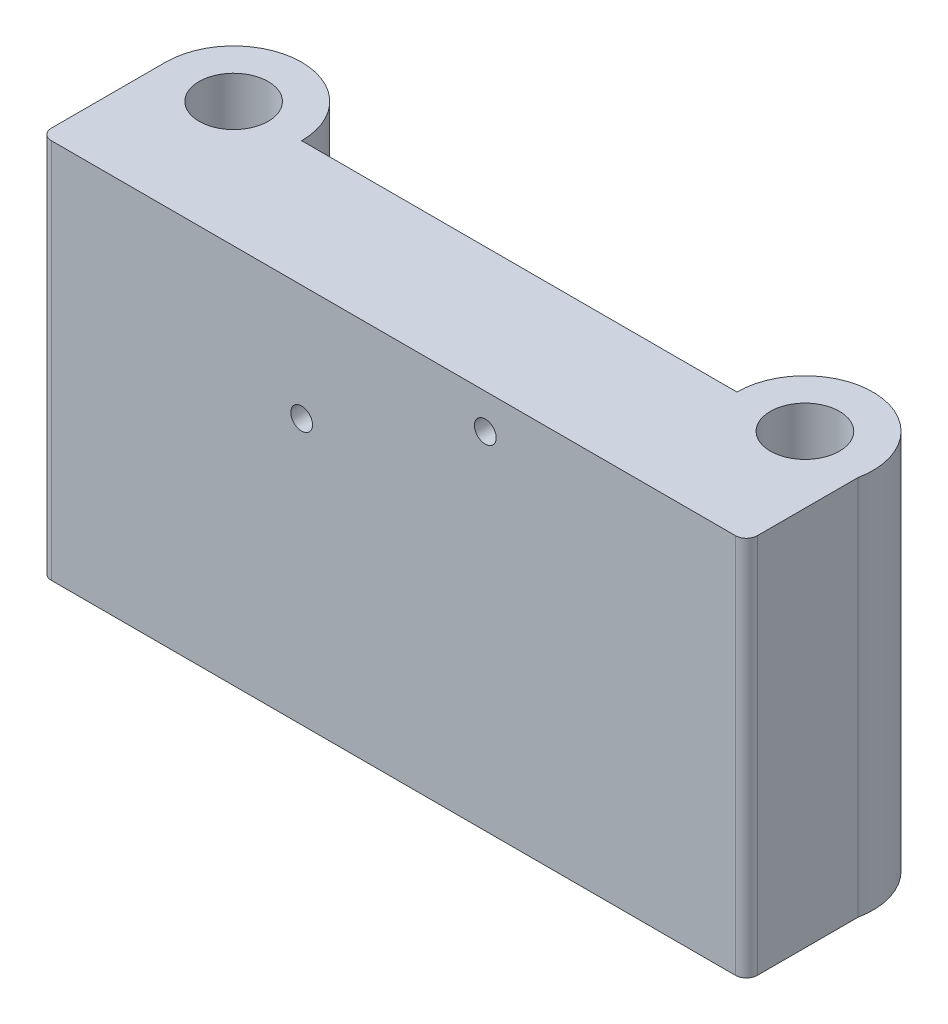
from build123d import *

# Parameters (mm, degrees)
BOSS_EXTRUDE1_DEPTH = 35
SKETCH2_R           = 3.175
CUT_EXTRUDE1_DEPTH  = 36
SKETCH3_R           = 4.25
CUT_EXTRUDE2_DEPTH  = 9
SKETCH4_R           = 1
CUT_EXTRUDE4_DEPTH  = 18.75
FILLET1_R           = 1


with BuildPart() as part:
    # Sketch1 → Boss-Extrude1 (new body)
    with BuildSketch(Plane(origin=(0, 0, 0), x_dir=(1, 0, 0), z_dir=(0, 1, 0))):
        with BuildLine():
            Line((-24.985807588, 0), (15.020468055, 0))
            ThreePointArc((15.020468055, 0), (21.898649068, 6.218350956), (27.394192412, -1.25))
            Line((27.394192412, -1.25), (27.394192412, -11.5))
            Line((27.394192412, -11.5), (-37.485807588, -11.5))
            Line((-37.485807588, -11.5), (-37.485807588, 0))
            ThreePointArc((-37.485807588, 0), (-31.235807588, 6.25), (-24.985807588, 0))
        make_face()
    extrude(amount=BOSS_EXTRUDE1_DEPTH)

    # Sketch2 → Cut-Extrude1 (cut, through all)
    with BuildSketch(Plane(origin=(0, 35, 0), x_dir=(1, 0, 0), z_dir=(0, 1, 0))):
        with Locations((-31.235807588, 0)):
            Circle(SKETCH2_R)
        with Locations((21.270468055, 0)):
            Circle(SKETCH2_R)
    extrude(amount=-CUT_EXTRUDE1_DEPTH, mode=Mode.SUBTRACT)

    # Sketch3 → Cut-Extrude2 (cut)
    with BuildSketch(Plane.XZ):
        with Locations((21.270468055, 0)):
            Circle(SKETCH3_R)
        with Locations((-31.235807588, 0)):
            Circle(SKETCH3_R)
    extrude(amount=-CUT_EXTRUDE2_DEPTH, mode=Mode.SUBTRACT)

    # Sketch4 → Cut-Extrude4 (cut, through all)
    with BuildSketch(Plane.XY.offset(11.5)):
        with Locations((-13.485807588, 24.385)):
            Circle(SKETCH4_R)
        with Locations((3.394192412, 31.785)):
            Circle(SKETCH4_R)
    extrude(amount=-CUT_EXTRUDE4_DEPTH, mode=Mode.SUBTRACT)

    # Fillet1
    fillet1_edges = [part.edges().sort_by_distance(p)[0] for p in [
        (27.394192412, 17.5, 11.5),
        (-37.485807588, 17.5, 11.5),
    ]]
    fillet(fillet1_edges, radius=FILLET1_R)


solid = part.part
